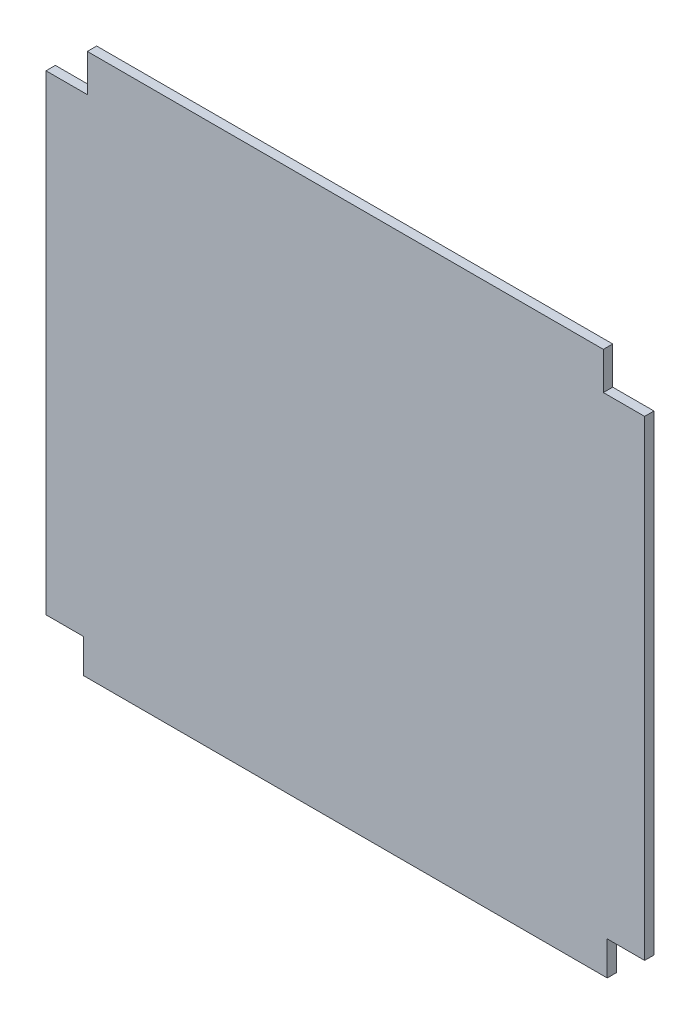
from build123d import *

# Parameters (mm, degrees)
BOSS_EXTRU_2_DEPTH = 10


with BuildPart() as part:
    # Esquisse1 → Boss.-Extru.2 (new body)
    with BuildSketch(Plane.XY):
        Polygon((-280, -290), (280, -290), (280, -253.75), (320, -253.75), (320, 250), (275.862068966, 250), (275.862068966, 290), (-275.862068966, 290), (-275.862068966, 250), (-320, 250), (-320, -253.75), (-280, -253.75), align=None)
    extrude(amount=BOSS_EXTRU_2_DEPTH)


solid = part.part
